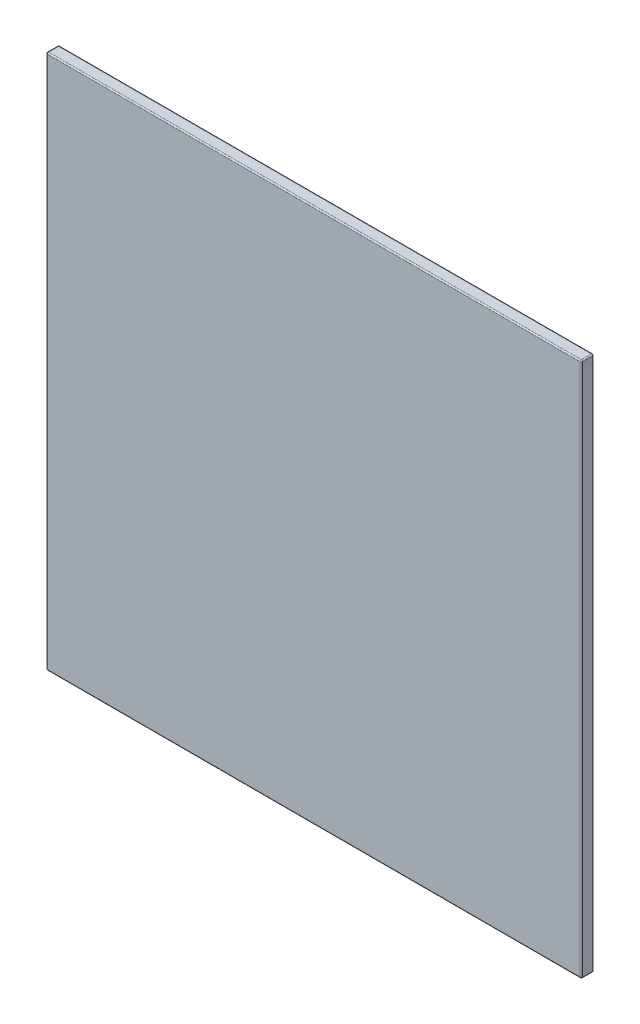
from build123d import *

# Parameters (mm, degrees)
SKETCH1_W           = 300
SKETCH1_H           = 300
BOSS_EXTRUDE1_DEPTH = 7
FILLET1_R           = 0.7


with BuildPart() as part:
    # Sketch1 → Boss-Extrude1 (new body)
    with BuildSketch(Plane.XY):
        with Locations((-23.291925466, 83.385093168)):
            Rectangle(SKETCH1_W, SKETCH1_H)
    extrude(amount=BOSS_EXTRUDE1_DEPTH)

    # Fillet1
    fillet1_edges = [part.edges().sort_by_distance(p)[0] for p in [
        (-173.291925466, 83.385093168, 7),
        (-23.291925466, -66.614906832, 7),
        (126.708074534, 83.385093168, 7),
        (-23.291925466, -66.614906832, 0),
        (-173.291925466, 83.385093168, 0),
        (-23.291925466, 233.385093168, 0),
        (126.708074534, 83.385093168, 0),
        (-23.291925466, 233.385093168, 7),
        (126.708074534, -66.614906832, 3.5),
        (-173.291925466, -66.614906832, 3.5),
        (-173.291925466, 233.385093168, 3.5),
        (126.708074534, 233.385093168, 3.5),
    ]]
    fillet(fillet1_edges, radius=FILLET1_R)


solid = part.part
